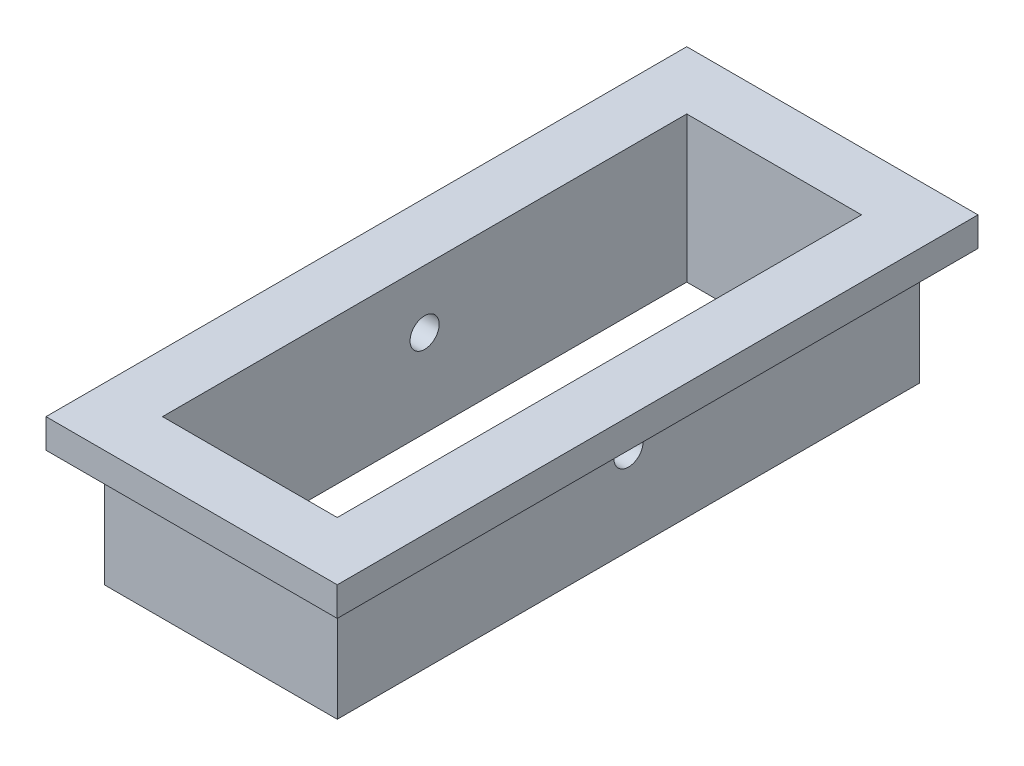
from build123d import *

# Parameters (mm, degrees)
SKETCH1_W               = 10.16
SKETCH1_H               = 25.4
SKETCH1_W_2             = 7.62
SKETCH1_H_2             = 22.86
BOSS_EXTRUDE1_DEPTH     = 6.35
SKETCH2_W               = 12.7
SKETCH2_H               = 27.94
SKETCH2_W_2             = 10.16
SKETCH2_H_2             = 25.4
BOSS_EXTRUDE2_DEPTH     = 1.27
SKETCH3_R               = 0.635
CUT_EXTRUDE1_DEPTH      = 11.16
CUT_EXTRUDE1_DEPTH_BACK = 3.54


with BuildPart() as part:
    # Sketch1 → Boss-Extrude1 (new body)
    with BuildSketch(Plane(origin=(0, 0, 0), x_dir=(1, 0, 0), z_dir=(0, 1, 0))):
        Rectangle(SKETCH1_W, SKETCH1_H)
        Rectangle(SKETCH1_W_2, SKETCH1_H_2, mode=Mode.SUBTRACT)
    extrude(amount=BOSS_EXTRUDE1_DEPTH)

    # Sketch2 → Boss-Extrude2 (add)
    with BuildSketch(Plane(origin=(0, 6.35, 0), x_dir=(1, 0, 0), z_dir=(0, 1, 0))):
        Rectangle(SKETCH2_W, SKETCH2_H)
        Rectangle(SKETCH2_W_2, SKETCH2_H_2, mode=Mode.SUBTRACT)
    extrude(amount=-BOSS_EXTRUDE2_DEPTH)

    # Sketch3 → Cut-Extrude1 (cut, two sides)
    with BuildSketch(Plane.ZY.offset(-3.81)) as cut_extrude1_sk:
        with Locations((0, 3.81)):
            Circle(SKETCH3_R)
    extrude(amount=CUT_EXTRUDE1_DEPTH, mode=Mode.SUBTRACT)
    extrude(cut_extrude1_sk.sketch, amount=-CUT_EXTRUDE1_DEPTH_BACK, mode=Mode.SUBTRACT)


solid = part.part
